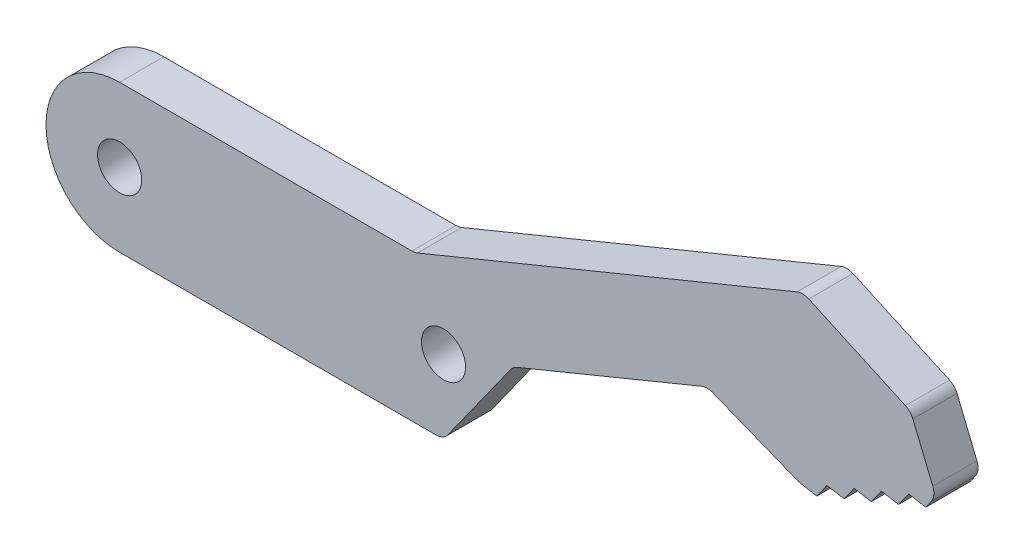
from build123d import *

# Parameters (mm, degrees)
SKETCH1_R           = 1.5
BOSS_EXTRUDE1_DEPTH = 3
FILLET1_R           = 1


with BuildPart() as part:
    # Sketch1 → Boss-Extrude1 (new body)
    with BuildSketch(Plane.XY):
        with BuildLine():
            Line((20.05, 5), (0, 5))
            ThreePointArc((0, 5), (-5, 0), (0, -5))
            Line((0, -5), (22, -5))
            Line((22, -5), (26.72989842, 1.621129525))
            Line((26.72989842, 1.621129525), (39.900164389, 7.036080522))
            Line((39.900164389, 7.036080522), (46.188488025, 4.540007042))
            Line((46.188488025, 4.540007042), (47.352932204, 4.337597171))
            Line((47.352932204, 4.337597171), (48.038244482, 5.300533868))
            Line((48.038244482, 5.300533868), (49.20268866, 5.098123997))
            Line((49.20268866, 5.098123997), (49.888000938, 6.061060693))
            Line((49.888000938, 6.061060693), (51.052445116, 5.858650822))
            Line((51.052445116, 5.858650822), (51.737757394, 6.821587519))
            Line((51.737757394, 6.821587519), (52.902201573, 6.619177648))
            Line((52.902201573, 6.619177648), (53.587513851, 7.582114344))
            Line((53.587513851, 7.582114344), (54.751958029, 7.379704473))
            Line((54.751958029, 7.379704473), (55.437270307, 8.34264117))
            Line((55.437270307, 8.34264117), (53.72608495, 12.504593197))
            Line((53.72608495, 12.504593197), (46.409029503, 15.837507263))
            Line((46.409029503, 15.837507263), (20.05, 5))
        make_face()
        Circle(SKETCH1_R, mode=Mode.SUBTRACT)
        with Locations((22, 0)):
            Circle(SKETCH1_R, mode=Mode.SUBTRACT)
    extrude(amount=BOSS_EXTRUDE1_DEPTH)

    # Fillet1
    fillet1_edges = [part.edges().sort_by_distance(p)[0] for p in [
        (22, -5, 1.5),
        (20.05, 5, 1.5),
        (46.409029503, 15.837507263, 1.5),
        (53.72608495, 12.504593197, 1.5),
        (55.437270307, 8.34264117, 1.5),
        (46.188488025, 4.540007042, 1.5),
        (39.900164389, 7.036080522, 1.5),
        (26.72989842, 1.621129525, 1.5),
    ]]
    fillet(fillet1_edges, radius=FILLET1_R)


solid = part.part
